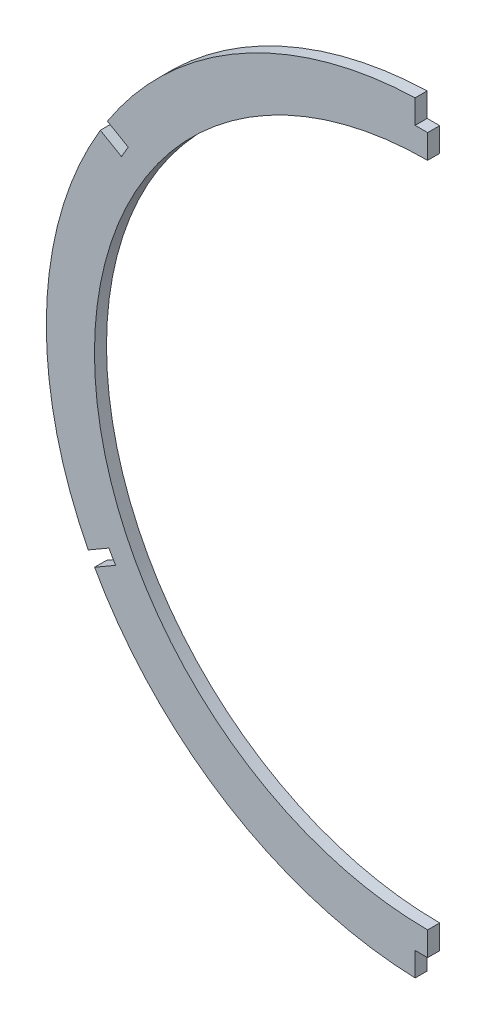
from build123d import *

# Parameters (mm, degrees)
BOSS_EXTRUDE1_DEPTH = 3.175
SKETCH3_W           = 149.303507008
SKETCH3_H           = 288.678903575
CUT_EXTRUDE1_DEPTH  = 101.601825752
SKETCH4_W           = 3.302
SKETCH4_H           = 7.449124121
SKETCH4_H_2         = 9.965839279
CUT_EXTRUDE2_DEPTH  = 4.175


with BuildPart() as part:
    # Sketch2 → Boss-Extrude1 (new body)
    with BuildSketch(Plane.XY):
        with BuildLine():
            ThreePointArc((-1.783927604, 106.664181958), (-86.289926541, 57.796410124), (-89.548347912, -39.767444199))
            ThreePointArc((-89.548347912, -39.767444199), (-89.139366423, -40.557656379), (-88.723411943, -41.344220438))
            ThreePointArc((-88.723411943, -41.344220438), (-88.300763494, -42.126623343), (-87.87121564, -42.905259753))
            ThreePointArc((-87.87121564, -42.905259753), (0, -94.523651503), (87.87121564, -42.905259753))
            ThreePointArc((87.87121564, -42.905259753), (88.300763494, -42.126623343), (88.723411943, -41.344220438))
            ThreePointArc((88.723411943, -41.344220438), (89.139366423, -40.557656379), (89.548347912, -39.767444199))
            ThreePointArc((89.548347912, -39.767444199), (86.289926541, 57.796410124), (1.783927604, 106.664181958))
            ThreePointArc((1.783927604, 106.664181958), (0.891998866, 106.676045412), (0, 106.68))
            ThreePointArc((0, 106.68), (-0.891998866, 106.676045412), (-1.783927604, 106.664181958))
        make_face()
        with BuildLine():
            ThreePointArc((-7.652045127, 93.646303016), (0, -81.823651503), (7.652045127, 93.646303016))
            ThreePointArc((7.652045127, 93.646303016), (4.717664566, 93.853310885), (1.778000524, 93.962016248))
            ThreePointArc((1.778000524, 93.962016248), (0.889045735, 93.975503947), (0, 93.98))
            ThreePointArc((0, 93.98), (-0.889045735, 93.975503947), (-1.778000524, 93.962016248))
            ThreePointArc((-1.778000524, 93.962016248), (-4.717664566, 93.853310885), (-7.652045127, 93.646303016))
        make_face(mode=Mode.SUBTRACT)
    extrude(amount=-BOSS_EXTRUDE1_DEPTH)

    # Sketch3 → Cut-Extrude1 (cut, through all)
    with BuildSketch(Plane(origin=(0, 0, 0), x_dir=(0, 0, -1), z_dir=(1, 0, 0))):
        with Locations((2.160275602, 8.369276658)):
            Rectangle(SKETCH3_W, SKETCH3_H)
    extrude(amount=CUT_EXTRUDE1_DEPTH, mode=Mode.SUBTRACT)

    # Sketch4 → Cut-Extrude2 (cut, through all)
    with BuildSketch(Plane.XY):
        Polygon((-88.109110822, 62.776111712), (-78.996562371, 57.51497941), (-80.761862371, 54.45739012), (-89.874410822, 59.718522421), align=None)
        Polygon((-84.09504483, -36.64600391), (-82.32974483, -39.7035932), (-90.457535691, -44.396175442), (-92.222835691, -41.338586151), align=None)
        with Locations((-1.651, -91.898213564)):
            Rectangle(SKETCH4_W, SKETCH4_H)
        with Locations((-1.651, 105.31291964)):
            Rectangle(SKETCH4_W, SKETCH4_H_2)
    extrude(amount=-CUT_EXTRUDE2_DEPTH, mode=Mode.SUBTRACT)


solid = part.part
